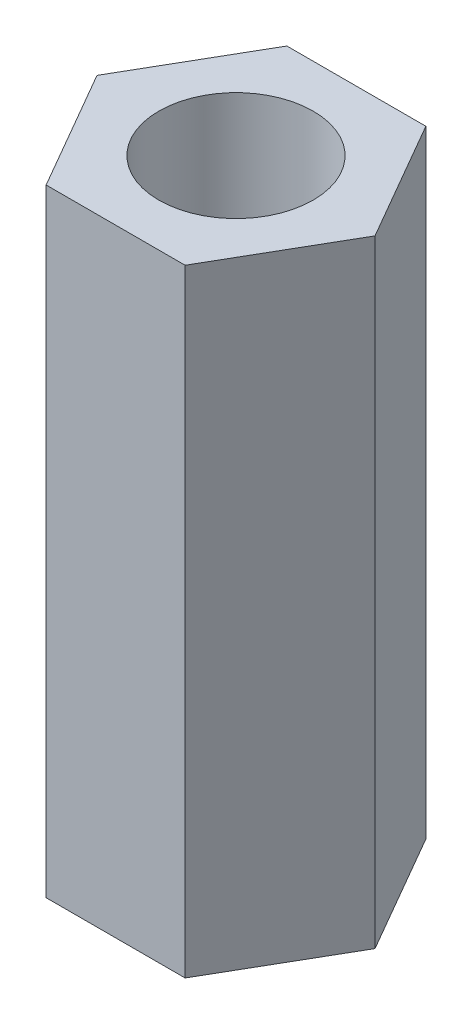
from build123d import *

# Parameters (mm, degrees)
EXTRUDE_1_DEPTH     = 10
SKETCH_2_R          = 1.25
CUT_EXTRUDE_1_DEPTH = 11


with BuildPart() as part:
    # 草图1 → 凸台-拉伸1 (new body)
    with BuildSketch(Plane(origin=(0, 0, 0), x_dir=(1, 0, 0), z_dir=(0, 1, 0))):
        Polygon((2.25166605, 0), (1.125833025, 1.95), (-1.125833025, 1.95), (-2.25166605, 0), (-1.125833025, -1.95), (1.125833025, -1.95), align=None)
    extrude(amount=EXTRUDE_1_DEPTH)

    # 草图2 → 切除-拉伸1 (cut, through all)
    with BuildSketch(Plane(origin=(0, 10, 0), x_dir=(1, 0, 0), z_dir=(0, 1, 0))):
        Circle(SKETCH_2_R)
    extrude(amount=-CUT_EXTRUDE_1_DEPTH, mode=Mode.SUBTRACT)


solid = part.part
